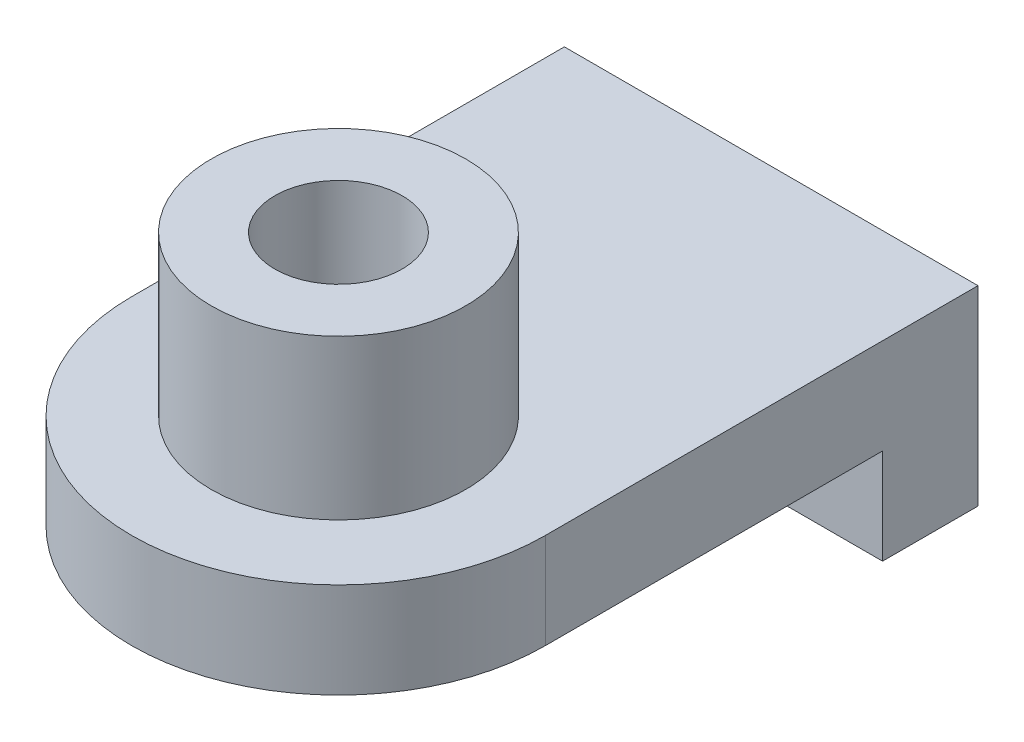
from build123d import *

# Parameters (mm, degrees)
SKETCH3_R                = 20
SKETCH3_R_2              = 10
BOSS_EXTRUDE4_DEPTH      = 40
SKETCH3_7_R              = 20
BOSS_EXTRUDE5_DEPTH      = 15
BOSS_EXTRUDE6_DEPTH      = 15
BOSS_EXTRUDE6_DEPTH_BACK = 15
SKETCH3_8_W              = 65
SKETCH3_8_H              = 15


with BuildPart() as part:
    # Sketch3 → Boss-Extrude4 (new body)
    with BuildSketch(Plane(origin=(0, 0, 0), x_dir=(1, 0, 0), z_dir=(0, 1, 0))):
        Circle(SKETCH3_R)
        Circle(SKETCH3_R_2, mode=Mode.SUBTRACT)
    extrude(amount=BOSS_EXTRUDE4_DEPTH)

    # Sketch3_7 → Boss-Extrude5 (add)
    with BuildSketch(Plane(origin=(0, 0, 0), x_dir=(1, 0, 0), z_dir=(0, 1, 0))):
        with BuildLine():
            Line((32.5, 53), (-32.5, 53))
            Line((-32.5, 53), (-32.5, 0))
            ThreePointArc((-32.5, 0), (0, -32.5), (32.5, 0))
            Line((32.5, 0), (32.5, 53))
        make_face()
        Circle(SKETCH3_7_R, mode=Mode.SUBTRACT)
    extrude(amount=BOSS_EXTRUDE5_DEPTH)

    # Sketch3_8 → Boss-Extrude6 (add, two sides: drawn at the far end of the back side and taken through both)
    with BuildSketch(Plane(origin=(0, 0, 0), x_dir=(1, 0, 0), z_dir=(0, 1, 0)).offset(-BOSS_EXTRUDE6_DEPTH_BACK)):
        with Locations((0, 60.5)):
            Rectangle(SKETCH3_8_W, SKETCH3_8_H)
    extrude(amount=BOSS_EXTRUDE6_DEPTH + BOSS_EXTRUDE6_DEPTH_BACK)


solid = part.part
